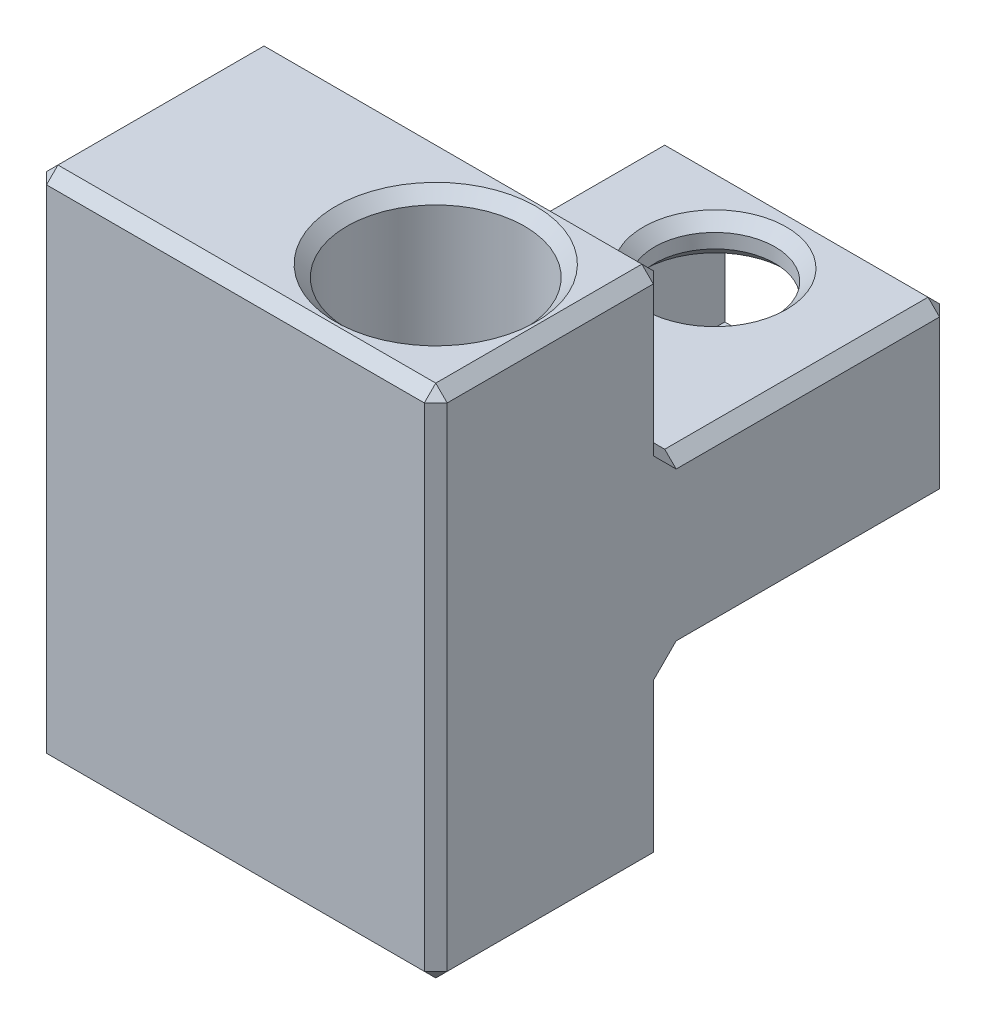
from build123d import *

# Parameters (mm, degrees)
SKETCH1_W               = 35
SKETCH1_H               = 20
BOSS_EXTRUDE1_DEPTH     = 45
SKETCH2_R               = 7.75
CUT_EXTRUDE1_DEPTH      = 46
SKETCH10_R              = 4.25
CUT_EXTRUDE6_DEPTH      = 10
SKETCH4_W               = 25
SKETCH4_H               = 15
BOSS_EXTRUDE2_DEPTH     = 25
SKETCH5_W               = 14.5
SKETCH5_H               = 16.25
CUT_EXTRUDE3_DEPTH      = 31
BOSS_EXTRUDE3_REACH     = 21.75
SKETCH6_W               = 16.25
SKETCH6_H               = 3.25
SKETCH7_R               = 5.25
CUT_EXTRUDE4_DEPTH      = 27.75
CUT_EXTRUDE4_DEPTH_BACK = 19.25
CHAMFER1_SIZE           = 1


with BuildPart() as part:
    # Sketch1 → Boss-Extrude1 (new body)
    with BuildSketch(Plane(origin=(0, 0, 0), x_dir=(1, 0, 0), z_dir=(0, 1, 0))):
        with Locations((17.5, 10)):
            Rectangle(SKETCH1_W, SKETCH1_H)
    extrude(amount=BOSS_EXTRUDE1_DEPTH)

    # Sketch2 → Cut-Extrude1 (cut, through all)
    with BuildSketch(Plane(origin=(0, 45, 0), x_dir=(1, 0, 0), z_dir=(0, 1, 0))):
        with Locations((25, 10)):
            Circle(SKETCH2_R)
    extrude(amount=-CUT_EXTRUDE1_DEPTH, mode=Mode.SUBTRACT)

    # Sketch10 → Cut-Extrude6 (cut)
    with BuildSketch(Plane.ZY):
        with Locations((-10, 37.6875)):
            Circle(SKETCH10_R)
        with Locations((-10, 7.3125)):
            Circle(SKETCH10_R)
    extrude(amount=-CUT_EXTRUDE6_DEPTH, mode=Mode.SUBTRACT)

    # Sketch4 → Boss-Extrude2 (add)
    with BuildSketch(Plane(origin=(0, 0, -20), x_dir=(-1, 0, 0), z_dir=(0, 0, -1))):
        with Locations((-22.5, 22.5)):
            Rectangle(SKETCH4_W, SKETCH4_H)
    extrude(amount=BOSS_EXTRUDE2_DEPTH)

    # Sketch5 → Cut-Extrude3 (cut, through all)
    with BuildSketch(Plane(origin=(0, 30, 0), x_dir=(1, 0, 0), z_dir=(0, 1, 0))):
        with Locations((22.5, 36.875)):
            Rectangle(SKETCH5_W, SKETCH5_H)
    extrude(amount=-CUT_EXTRUDE3_DEPTH, mode=Mode.SUBTRACT)

    # Sketch6 → Boss-Extrude3 (add, up to next)
    with BuildSketch(Plane(origin=(15.25, 0, 0), x_dir=(0, 0, -1), z_dir=(1, 0, 0)), mode=Mode.PRIVATE) as boss_extrude3_sk1:
        with Locations((36.875, 28.375)):
            Rectangle(SKETCH6_W, SKETCH6_H)
    boss_extrude3_tool1 = extrude(boss_extrude3_sk1.sketch, amount=BOSS_EXTRUDE3_REACH, mode=Mode.PRIVATE) - part.part
    add(boss_extrude3_tool1.solids().sort_by_distance((15.25, 28.375, -36.875))[0])
    # Sketch6 → Boss-Extrude3 (add, up to next)
    with BuildSketch(Plane(origin=(15.25, 0, 0), x_dir=(0, 0, -1), z_dir=(1, 0, 0)), mode=Mode.PRIVATE) as boss_extrude3_sk2:
        with Locations((36.875, 16.625)):
            Rectangle(SKETCH6_W, SKETCH6_H)
    boss_extrude3_tool2 = extrude(boss_extrude3_sk2.sketch, amount=BOSS_EXTRUDE3_REACH, mode=Mode.PRIVATE) - part.part
    add(boss_extrude3_tool2.solids().sort_by_distance((15.25, 16.625, -36.875))[0])

    # Sketch7 → Cut-Extrude4 (cut, two sides)
    with BuildSketch(Plane(origin=(0, 18.25, 0), x_dir=(1, 0, 0), z_dir=(0, 1, 0))) as cut_extrude4_sk:
        with Locations((22.5, 36.875)):
            Circle(SKETCH7_R)
    extrude(amount=CUT_EXTRUDE4_DEPTH, mode=Mode.SUBTRACT)
    extrude(cut_extrude4_sk.sketch, amount=-CUT_EXTRUDE4_DEPTH_BACK, mode=Mode.SUBTRACT)

    # Chamfer1
    chamfer1_edges = [part.edges().sort_by_distance(p)[0] for p in [
        (35, 45, -10),
        (17.25, 0, -10),
        (17.25, 45, -10),
        (17.5, 45, -20),
        (0, 37.6875, -14.25),
        (0, 7.3125, -14.25),
        (35, 7.5, -20),
        (10, 22.5, -20),
        (22.5, 30, -20),
        (10, 30, -32.5),
        (35, 30, -32.5),
        (22.5, 15, -20),
        (35, 15, -32.5),
        (22.5, 30, -45),
        (35, 22.5, -45),
        (22.5, 15, -45),
        (0, 45, -10),
        (17.5, 0, -20),
        (35, 0, -10),
        (17.5, 0, 0),
        (0, 0, -10),
        (0, 22.5, -20),
        (35, 37.5, -20),
        (35, 22.5, 0),
        (0, 22.5, 0),
        (17.25, 26.75, -36.875),
        (17.25, 30, -36.875),
        (17.25, 18.25, -36.875),
        (17.25, 15, -36.875),
        (17.5, 45, 0),
    ]]
    chamfer(chamfer1_edges, length=CHAMFER1_SIZE)


solid = part.part
